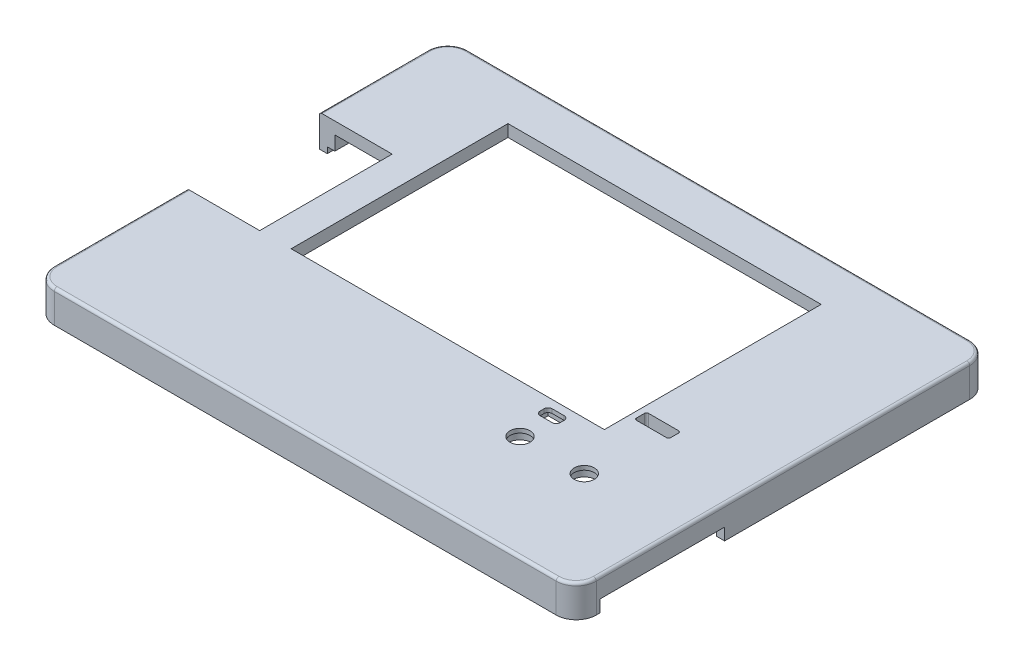
from build123d import *

# Parameters (mm, degrees)
SKETCH1_W                = 135
SKETCH1_H                = 103
BOSS_EXTRUDE1_DEPTH      = 8
SKETCH2_W                = 127.2
SKETCH2_H                = 95.2
CUT_EXTRUDE1_DEPTH       = 5
SKETCH3_W                = 131
SKETCH3_H                = 99
CUT_EXTRUDE2_DEPTH       = 1.5
SKETCH4_W                = 31
SKETCH4_H                = 3
CUT_EXTRUDE3_DEPTH       = 5
SKETCH5_W                = 33
SKETCH5_H                = 12
CUT_EXTRUDE4_DEPTH       = 17.5
SKETCH6_W                = 78
SKETCH6_H                = 54
CUT_EXTRUDE5_DEPTH       = 12
SKETCH7_W                = 8.2
SKETCH7_H                = 4
CUT_EXTRUDE6_DEPTH       = 12
SKETCH8_W                = 8.2
SKETCH8_H                = 4
CUT_EXTRUDE7_DEPTH       = 12
SKETCH9_R                = 2.5
CUT_EXTRUDE8_DEPTH       = 12
SKETCH13_R               = 2.5
CUT_EXTRUDE11_DEPTH      = 5
SKETCH14_W               = 5
SKETCH14_H               = 3
CUT_EXTRUDE12_DEPTH      = 5
FILLET1_R                = 1
SKETCH16_W               = 8.5
SKETCH16_H               = 3
CUT_EXTRUDE14_DEPTH      = 3
FILLET2_R                = 0.5
FILLET4_R                = 5
FILLET5_R                = 0.7
CUT_EXTRUDE16_DEPTH      = 9.3
CUT_EXTRUDE16_DEPTH_BACK = 1.1
CUT_EXTRUDE17_DEPTH      = 9.3
CUT_EXTRUDE17_DEPTH_BACK = 1.1
SKETCH20_W               = 10.4
SKETCH20_H               = 3.9
CUT_EXTRUDE18_DEPTH      = 3.1
SKETCH24_W               = 10.4
SKETCH24_H               = 4.885923936
CUT_EXTRUDE27_DEPTH      = 3.1
SCALE1_SCALE             = 1.015
SKETCH25_R               = 3.25
SKETCH25_W               = 7.075
SKETCH25_H               = 5.045
CUT_EXTRUDE28_DEPTH      = 2
CUT_EXTRUDE29_DEPTH      = 0.3
CUT_EXTRUDE30_DEPTH      = 0.3
CUT_EXTRUDE31_DEPTH      = 0.41
CUT_EXTRUDE32_DEPTH      = 0.2
SKETCH31_W               = 33.495
SKETCH31_H               = 3.045
CUT_EXTRUDE33_DEPTH      = 0.6725


with BuildPart() as part:
    # Sketch1 → Boss-Extrude1 (new body)
    with BuildSketch(Plane(origin=(0, 0, 0), x_dir=(1, 0, 0), z_dir=(0, 1, 0))):
        Rectangle(SKETCH1_W, SKETCH1_H)
    extrude(amount=BOSS_EXTRUDE1_DEPTH)

    # Sketch2 → Cut-Extrude1 (cut)
    with BuildSketch(Plane.XZ):
        Rectangle(SKETCH2_W, SKETCH2_H)
    extrude(amount=-CUT_EXTRUDE1_DEPTH, mode=Mode.SUBTRACT)

    # Sketch3 → Cut-Extrude2 (cut)
    with BuildSketch(Plane.XZ):
        Rectangle(SKETCH3_W, SKETCH3_H)
    extrude(amount=-CUT_EXTRUDE2_DEPTH, mode=Mode.SUBTRACT)

    # Sketch4 → Cut-Extrude3 (cut)
    with BuildSketch(Plane(origin=(67.5, 0, 0), x_dir=(0, 0, -1), z_dir=(1, 0, 0))):
        with Locations((-30.05, 1.5)):
            Rectangle(SKETCH4_W, SKETCH4_H)
    extrude(amount=-CUT_EXTRUDE3_DEPTH, mode=Mode.SUBTRACT)

    # Sketch5 → Cut-Extrude4 (cut)
    with BuildSketch(Plane.ZY.offset(67.5)):
        with Locations((-3, 6)):
            Rectangle(SKETCH5_W, SKETCH5_H)
    extrude(amount=-CUT_EXTRUDE4_DEPTH, mode=Mode.SUBTRACT)

    # Sketch6 → Cut-Extrude5 (cut)
    with BuildSketch(Plane(origin=(0, 8, 0), x_dir=(1, 0, 0), z_dir=(0, 1, 0))):
        with Locations((-2.5, 13.5)):
            Rectangle(SKETCH6_W, SKETCH6_H)
    extrude(amount=-CUT_EXTRUDE5_DEPTH, mode=Mode.SUBTRACT)

    # Sketch7 → Cut-Extrude6 (cut)
    with BuildSketch(Plane(origin=(0, 0, -51.5), x_dir=(-1, 0, 0), z_dir=(0, 0, -1))):
        with Locations((-56.5, 2)):
            Rectangle(SKETCH7_W, SKETCH7_H)
    extrude(amount=-CUT_EXTRUDE6_DEPTH, mode=Mode.SUBTRACT)

    # Sketch8 → Cut-Extrude7 (cut)
    with BuildSketch(Plane(origin=(0, 0, -51.5), x_dir=(-1, 0, 0), z_dir=(0, 0, -1))):
        with Locations((-41.5, 2)):
            Rectangle(SKETCH8_W, SKETCH8_H)
    extrude(amount=-CUT_EXTRUDE7_DEPTH, mode=Mode.SUBTRACT)

    # Sketch9 → Cut-Extrude8 (cut)
    with BuildSketch(Plane(origin=(0, 8, 0), x_dir=(1, 0, 0), z_dir=(0, 1, 0))):
        with Locations((43.5, -25.5)):
            Circle(SKETCH9_R)
    extrude(amount=-CUT_EXTRUDE8_DEPTH, mode=Mode.SUBTRACT)

    # Sketch13 → Cut-Extrude11 (cut)
    with BuildSketch(Plane(origin=(0, 8, 0), x_dir=(1, 0, 0), z_dir=(0, 1, 0))):
        with Locations((27.5, -25.5)):
            Circle(SKETCH13_R)
    extrude(amount=-CUT_EXTRUDE11_DEPTH, mode=Mode.SUBTRACT)

    # Sketch14 → Cut-Extrude12 (cut)
    with BuildSketch(Plane(origin=(0, 8, 0), x_dir=(1, 0, 0), z_dir=(0, 1, 0))):
        with Locations((27, -17)):
            Rectangle(SKETCH14_W, SKETCH14_H)
    extrude(amount=-CUT_EXTRUDE12_DEPTH, mode=Mode.SUBTRACT)

    # Fillet1
    fillet1_edges = [part.edges().sort_by_distance(p)[0] for p in [
        (29.5, 6.5, 15.5),
        (29.5, 6.5, 18.5),
        (24.5, 6.5, 18.5),
        (24.5, 6.5, 15.5),
    ]]
    fillet(fillet1_edges, radius=FILLET1_R)

    # Sketch16 → Cut-Extrude14 (cut)
    with BuildSketch(Plane(origin=(0, 8, 0), x_dir=(1, 0, 0), z_dir=(0, 1, 0))):
        with Locations((42.25, -6)):
            Rectangle(SKETCH16_W, SKETCH16_H)
    extrude(amount=-CUT_EXTRUDE14_DEPTH, mode=Mode.SUBTRACT)

    # Fillet2
    fillet2_edges = [part.edges().sort_by_distance(p)[0] for p in [
        (46.5, 6.5, 4.5),
        (46.5, 6.5, 7.5),
        (38, 6.5, 7.5),
        (38, 6.5, 4.5),
    ]]
    fillet(fillet2_edges, radius=FILLET2_R)

    # Fillet4
    fillet4_edges = [part.edges().sort_by_distance(p)[0] for p in [
        (67.5, 4, 51.5),
        (-67.5, 4, 51.5),
        (-67.5, 4, -51.5),
        (67.5, 4, -51.5),
    ]]
    fillet(fillet4_edges, radius=FILLET4_R)

    # Fillet5
    fillet5_edges = [part.edges().sort_by_distance(p)[0] for p in [
        (0, 8, -51.5),
        (67.5, 8, 0),
        (0, 8, 51.5),
        (-67.5, 8, -33),
        (-66.035533906, 8, -50.035533906),
        (-66.035533906, 8, 50.035533906),
        (66.035533906, 8, 50.035533906),
        (66.035533906, 8, -50.035533906),
        (-67.5, 8, 30),
    ]]
    fillet(fillet5_edges, radius=FILLET5_R)

    # Sketch18 → Cut-Extrude16 (cut, two sides)
    with BuildSketch(Plane.ZY.offset(-60.6)) as cut_extrude16_sk:
        Polygon((-51.5, 0), (-51.5, 4), (-47.6, 4), (-47.6, 1.5), (-49.5, 1.5), (-49.5, 0), align=None)
    extrude(amount=CUT_EXTRUDE16_DEPTH, mode=Mode.SUBTRACT)
    extrude(cut_extrude16_sk.sketch, amount=-CUT_EXTRUDE16_DEPTH_BACK, mode=Mode.SUBTRACT)

    # Sketch19 → Cut-Extrude17 (cut, two sides)
    with BuildSketch(Plane.ZY.offset(-45.6)) as cut_extrude17_sk:
        Polygon((-51.5, 0), (-51.5, 4), (-47.6, 4), (-47.6, 1.5), (-49.5, 1.5), (-49.5, 0), align=None)
    extrude(amount=CUT_EXTRUDE17_DEPTH, mode=Mode.SUBTRACT)
    extrude(cut_extrude17_sk.sketch, amount=-CUT_EXTRUDE17_DEPTH_BACK, mode=Mode.SUBTRACT)

    # Sketch20 → Cut-Extrude18 (cut)
    with BuildSketch(Plane.XZ.offset(-4)):
        with Locations((41.5, -49.55)):
            Rectangle(SKETCH20_W, SKETCH20_H)
    extrude(amount=-CUT_EXTRUDE18_DEPTH, mode=Mode.SUBTRACT)

    # Sketch24 → Cut-Extrude27 (cut)
    with BuildSketch(Plane.XZ.offset(-4)):
        with Locations((56.5, -49.704852534)):
            Rectangle(SKETCH24_W, SKETCH24_H)
    extrude(amount=-CUT_EXTRUDE27_DEPTH, mode=Mode.SUBTRACT)


with BuildPart() as part_1:
    # Scale1: scaled about (0, 0, 0)
    add(part.part.scale(SCALE1_SCALE))

    # Sketch25 → Cut-Extrude28 (cut)
    with BuildSketch(Plane.XZ.offset(-5.075)):
        with Locations((44.1525, 25.8825)):
            Circle(SKETCH25_R)
        with Locations((27.9125, 25.8825)):
            Circle(SKETCH25_R)
        with Locations((27.405, 17.255)):
            Rectangle(SKETCH25_W, SKETCH25_H)
    extrude(amount=-CUT_EXTRUDE28_DEPTH, mode=Mode.SUBTRACT)

    # Sketch26 → Cut-Extrude29 (cut)
    with BuildSketch(Plane.ZY.offset(-62.6255)):
        Polygon((-52.2725, 0), (-50.2425, 0), (-50.2425, 1.5225), (-48.314, 1.5225), (-48.314, 5.075), (-47.970818925, 5.075), (-47.970818925, 7.2065), (-52.2725, 7.2065), align=None)
    extrude(amount=-CUT_EXTRUDE29_DEPTH, mode=Mode.SUBTRACT)

    # Sketch27 → Cut-Extrude30 (cut)
    with BuildSketch(Plane(origin=(52.0695, 0, 0), x_dir=(0, 0, -1), z_dir=(1, 0, 0))):
        Polygon((50.2425, 0), (52.2725, 0), (52.2725, 7.2065), (47.970818925, 7.2065), (47.970818925, 5.075), (48.314, 5.075), (48.314, 1.5225), (50.2425, 1.5225), align=None)
    extrude(amount=-CUT_EXTRUDE30_DEPTH, mode=Mode.SUBTRACT)

    # Sketch28 → Cut-Extrude31 (cut)
    with BuildSketch(Plane.ZY.offset(-47.4005)):
        Polygon((-52.2725, 0), (-50.2425, 0), (-50.2425, 1.5225), (-48.314, 1.5225), (-48.314, 7.2065), (-52.2725, 7.2065), align=None)
    extrude(amount=-CUT_EXTRUDE31_DEPTH, mode=Mode.SUBTRACT)

    # Sketch29 → Cut-Extrude32 (cut)
    with BuildSketch(Plane(origin=(36.8445, 0, 0), x_dir=(0, 0, -1), z_dir=(1, 0, 0))):
        Polygon((50.2425, 0), (52.2725, 0), (52.2725, 7.2065), (48.314, 7.2065), (48.314, 1.5225), (50.2425, 1.5225), align=None)
    extrude(amount=-CUT_EXTRUDE32_DEPTH, mode=Mode.SUBTRACT)

    # Sketch31 → Cut-Extrude33 (cut)
    with BuildSketch(Plane.ZY.offset(50.75)):
        with Locations((-3.045, 6.5975)):
            Rectangle(SKETCH31_W, SKETCH31_H)
    extrude(amount=-CUT_EXTRUDE33_DEPTH, mode=Mode.SUBTRACT)


solid = part_1.part
